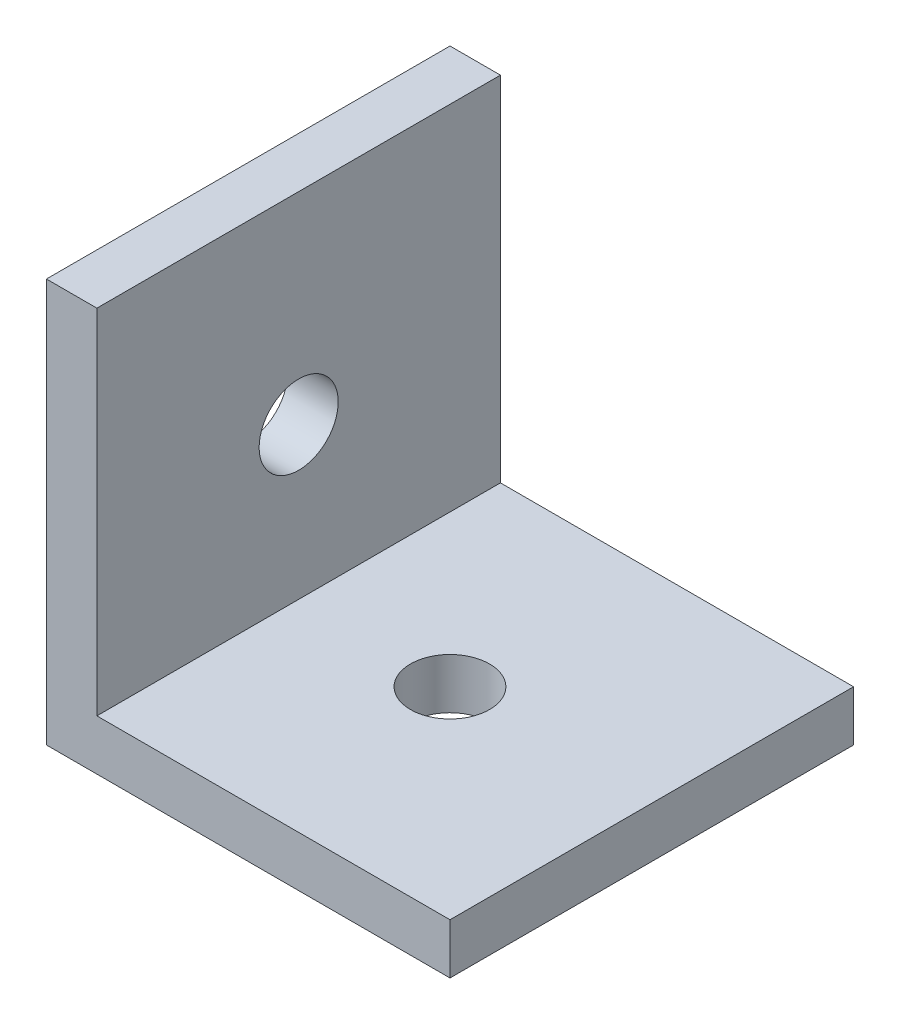
from build123d import *

# Parameters (mm, degrees)
EXTRUDE_THIN1_DEPTH = 12.7
SKETCH2_R           = 2.4892
CUT_EXTRUDE1_DEPTH  = 4.175


with BuildPart() as part:
    # Sketch1 → Extrude-Thin1 (new body, symmetric)
    with BuildSketch(Plane.XY):
        Polygon((0, 25.4), (0, 0), (25.4, 0), (25.4, 3.175), (3.175, 3.175), (3.175, 25.4), align=None)
    extrude(amount=EXTRUDE_THIN1_DEPTH, both=True)

    # Sketch2 → Cut-Extrude1 (cut, through all)
    with BuildSketch(Plane(origin=(0, 3.175, 0), x_dir=(1, 0, 0), z_dir=(0, 1, 0))):
        with Locations((12.7, 0)):
            Circle(SKETCH2_R)
    cut_extrude1 = extrude(amount=-CUT_EXTRUDE1_DEPTH, mode=Mode.SUBTRACT)

    # Mirror1: Cut-Extrude1 across plane
    add(cut_extrude1.mirror(Plane(origin=(0, 0, 0), x_dir=(0, 0, 1), z_dir=(0.707106781, -0.707106781, 0))), mode=Mode.SUBTRACT)


solid = part.part
